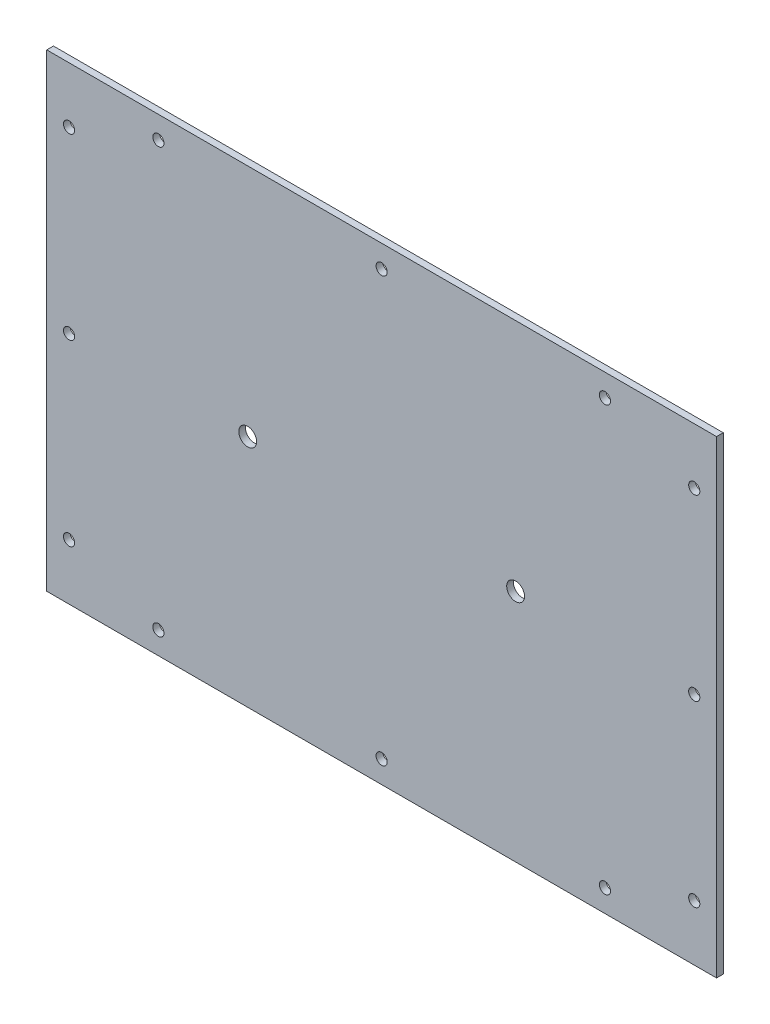
from build123d import *

# Parameters (mm, degrees)
CROQUIS1_W              = 300
CROQUIS1_H              = 210
SALIENTE_EXTRUIR1_DEPTH = 3
CROQUIS3_R              = 2.5
CORTAR_EXTRUIR1_DEPTH   = 4
CROQUIS4_R              = 4
CORTAR_EXTRUIR2_DEPTH   = 4


with BuildPart() as part:
    # Croquis1 → Saliente-Extruir1 (new body)
    with BuildSketch(Plane.XY):
        Rectangle(CROQUIS1_W, CROQUIS1_H)
    extrude(amount=SALIENTE_EXTRUIR1_DEPTH)

    # Croquis3 → Cortar-Extruir1 (cut, through all)
    with BuildSketch(Plane.XY.offset(3)):
        with Locations((0, 95)):
            Circle(CROQUIS3_R)
        with Locations((-140, 0)):
            Circle(CROQUIS3_R)
        with Locations((100, 95)):
            Circle(CROQUIS3_R)
        with Locations((-100, 95)):
            Circle(CROQUIS3_R)
        with Locations((-140, 80)):
            Circle(CROQUIS3_R)
        with Locations((-140, -80)):
            Circle(CROQUIS3_R)
        with Locations((100, -95)):
            Circle(CROQUIS3_R)
        with Locations((-100, -95)):
            Circle(CROQUIS3_R)
        with Locations((0, -95)):
            Circle(CROQUIS3_R)
        with Locations((140, -80)):
            Circle(CROQUIS3_R)
        with Locations((140, 80)):
            Circle(CROQUIS3_R)
        with Locations((140, 0)):
            Circle(CROQUIS3_R)
    extrude(amount=-CORTAR_EXTRUIR1_DEPTH, mode=Mode.SUBTRACT)

    # Croquis4 → Cortar-Extruir2 (cut, through all)
    with BuildSketch(Plane.XY.offset(3)):
        with Locations((-60, 0)):
            Circle(CROQUIS4_R)
        with Locations((60, 0)):
            Circle(CROQUIS4_R)
    extrude(amount=-CORTAR_EXTRUIR2_DEPTH, mode=Mode.SUBTRACT)


solid = part.part
